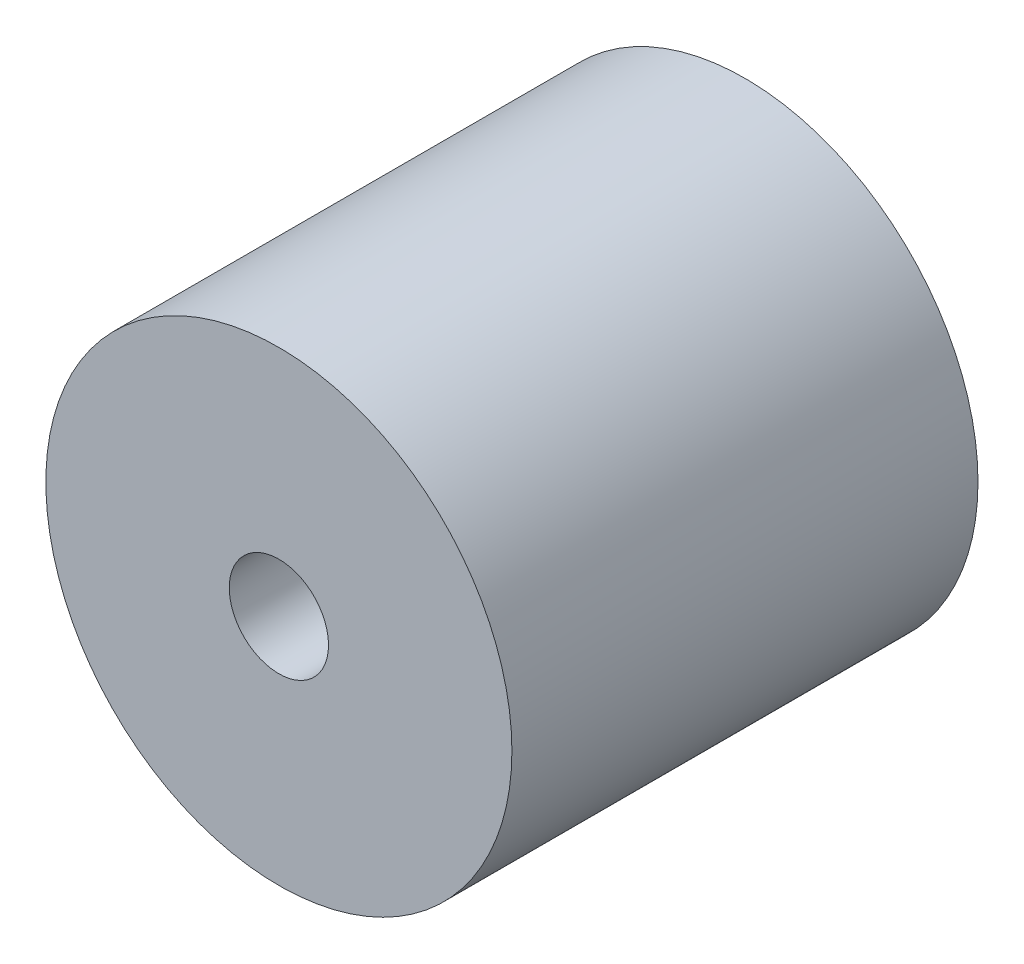
from build123d import *

# Parameters (mm, degrees)
SKETCH1_R               = 12.7
BOSS_EXTRUDE1_DEPTH     = 25.4
SKETCH2_R               = 10.4
CUT_EXTRUDE1_DEPTH      = 5.5
CUT_EXTRUDE2_START      = -1
SKETCH3_R               = 11.75
CUT_EXTRUDE2_DEPTH      = 1.8
F_1_4_28_TAPPED_HOLE1_D = 5.4102


with BuildPart() as part:
    # Sketch1 → Boss-Extrude1 (new body)
    with BuildSketch(Plane.XY):
        Circle(SKETCH1_R)
    extrude(amount=BOSS_EXTRUDE1_DEPTH)

    # Sketch2 → Cut-Extrude1 (cut)
    with BuildSketch(Plane(origin=(0, 0, 0), x_dir=(-1, 0, 0), z_dir=(0, 0, -1))):
        Circle(SKETCH2_R)
    extrude(amount=-CUT_EXTRUDE1_DEPTH, mode=Mode.SUBTRACT)

    # Sketch3 → Cut-Extrude2 (cut)
    with BuildSketch(Plane(origin=(0, 0, 0), x_dir=(-1, 0, 0), z_dir=(0, 0, -1)).offset(CUT_EXTRUDE2_START)):
        Circle(SKETCH3_R)
    extrude(amount=-CUT_EXTRUDE2_DEPTH, mode=Mode.SUBTRACT)

    # 1/4-28 Tapped Hole1 (through all)
    with Locations(Plane.XY.offset(25.4)):
        with Locations((0, 0)):
            Hole(F_1_4_28_TAPPED_HOLE1_D / 2)

    # Sketch10 → Cut-Revolve1 (revolve, cut)
    with BuildSketch(Plane(origin=(0, 0, 0), x_dir=(1, 0, 0), z_dir=(0, 1, 0))):
        Polygon((0, -25.402256059), (8.654624222, -5.5), (0, -5.5), align=None)
    revolve(axis=Axis((0, 0, 29.736025406), (0, 0, -1)), mode=Mode.SUBTRACT)


solid = part.part
